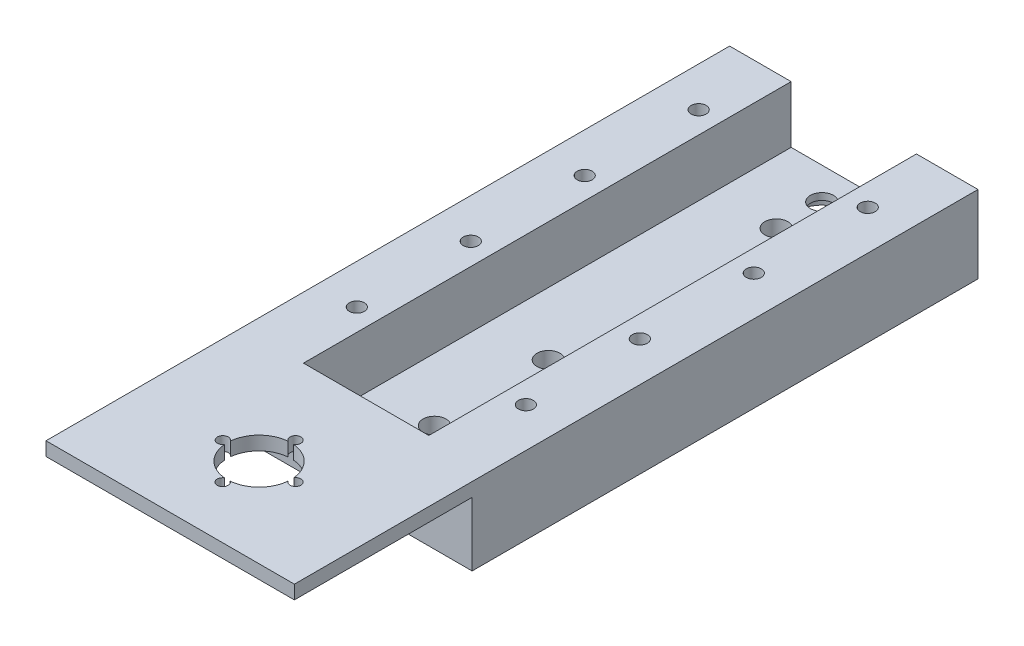
from build123d import *

# Parameters (mm, degrees)
SKETCH1_W                  = 54.5
SKETCH1_H                  = 111
BOSS_EXTRUDE1_DEPTH        = 4.5
SKETCH2_W                  = 13.5
SKETCH2_H                  = 111
BOSS_EXTRUDE2_DEPTH        = 12.5
M4X0_7_TAPPED_HOLE1_D      = 3.3
SKETCH6_W                  = 4
SKETCH6_H                  = 12.5
BOSS_EXTRUDE3_DEPTH        = 37
SKETCH7_W                  = 54.5
SKETCH7_H                  = 3
BOSS_EXTRUDE5_DEPTH        = 39
SKETCH8_R                  = 7
CUT_EXTRUDE1_DEPTH         = 3
M2_CLEARANCE_HOLE1_D       = 2.4
F_8_0_199_DIAMETER_HOLE1_D = 5.0546
SKETCH12_R                 = 5.5
CUT_EXTRUDE3_DEPTH         = 3
SKETCH13_W                 = 27.5
SKETCH13_H                 = 9.513667368
CUT_EXTRUDE4_DEPTH         = 5


with BuildPart() as part:
    # Sketch1 → Boss-Extrude1 (new body)
    with BuildSketch(Plane(origin=(0, 0, 0), x_dir=(1, 0, 0), z_dir=(0, 1, 0))):
        with Locations((-13.399543841, 44.129312584)):
            Rectangle(SKETCH1_W, SKETCH1_H)
    extrude(amount=BOSS_EXTRUDE1_DEPTH)

    # Sketch2 → Boss-Extrude2 (add)
    with BuildSketch(Plane(origin=(0, 4.5, 0), x_dir=(1, 0, 0), z_dir=(0, 1, 0))):
        with Locations((7.100456159, 44.129312584)):
            Rectangle(SKETCH2_W, SKETCH2_H)
        with Locations((-33.899543841, 44.129312584)):
            Rectangle(SKETCH2_W, SKETCH2_H)
    extrude(amount=BOSS_EXTRUDE2_DEPTH)

    # M4x0.7 Tapped Hole1 (through all)
    with Locations(Plane(origin=(-31.949543841, 17, -9.129312584), x_dir=(0, 0, 1), z_dir=(0, 1, 0))):
        with Locations((0, 0), (-25, 0), (-50, 0), (-75, 0), (0, 37.1), (-25, 37.1), (-50, 37.1), (-75, 37.1)):
            Hole(M4X0_7_TAPPED_HOLE1_D / 2)

    # Sketch6 → Boss-Extrude3 (add)
    with BuildSketch(Plane(origin=(-27.149543841, 0, 0), x_dir=(0, 0, -1), z_dir=(1, 0, 0))):
        with Locations((-9.370687416, 10.75)):
            Rectangle(SKETCH6_W, SKETCH6_H)
    extrude(amount=BOSS_EXTRUDE3_DEPTH)

    # Sketch7 → Boss-Extrude5 (add)
    with BuildSketch(Plane.XY.offset(11.370687416)):
        with Locations((-13.399543841, 15.5)):
            Rectangle(SKETCH7_W, SKETCH7_H)
    extrude(amount=BOSS_EXTRUDE5_DEPTH)

    # Sketch8 → Cut-Extrude1 (cut)
    with BuildSketch(Plane(origin=(0, 17, 0), x_dir=(1, 0, 0), z_dir=(0, 1, 0))):
        with Locations((-13.399543841, -30.870687416)):
            Circle(SKETCH8_R)
    extrude(amount=-CUT_EXTRUDE1_DEPTH, mode=Mode.SUBTRACT)

    # M2 Clearance Hole1 (through all)
    with Locations(Plane(origin=(-21.371437118, 17, 30.847906254), x_dir=(0, 0, 1), z_dir=(0, 1, 0))):
        with Locations((0, 0), (-7.977218838, 7.971893277), (8.022781162, 7.971893277), (-0.002806072, 15.940961576)):
            Hole(M2_CLEARANCE_HOLE1_D / 2)

    # #8 (0.199) Diameter Hole1 (through all)
    with Locations(Plane(origin=(-13.399543841, 4.5, 2.370687416), x_dir=(0, 0, 1), z_dir=(0, 1, 0))):
        with Locations((0, 0), (-10, 0), (-35, 0), (-85, 0), (-95, 0)):
            Hole(F_8_0_199_DIAMETER_HOLE1_D / 2)

    # Sketch12 → Cut-Extrude3 (cut)
    with BuildSketch(Plane(origin=(0, 0, 0), x_dir=(-1, 0, 0), z_dir=(0, -1, 0))):
        with Locations((13.399543841, 92.629312584)):
            Circle(SKETCH12_R)
    extrude(amount=-CUT_EXTRUDE3_DEPTH, mode=Mode.SUBTRACT)

    # Sketch13 → Cut-Extrude4 (cut)
    with BuildSketch(Plane.XY.offset(11.370687416)):
        with Locations((-13.399543841, 9.243166316)):
            Rectangle(SKETCH13_W, SKETCH13_H)
    extrude(amount=-CUT_EXTRUDE4_DEPTH, mode=Mode.SUBTRACT)


solid = part.part
